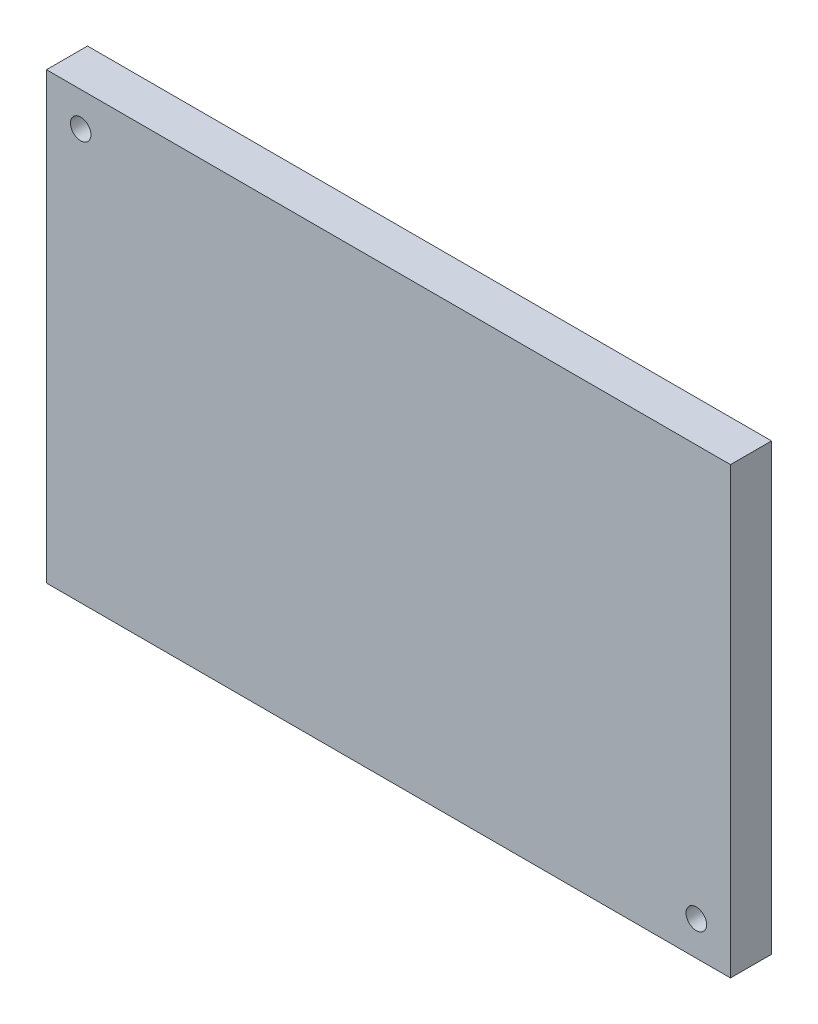
from build123d import *

# Parameters (mm, degrees)
ESQUISSE1_W             = 100
ESQUISSE1_H             = 65
BOSS_EXTRU_1_DEPTH      = 6
ESQUISSE2_R             = 1.5
ENL_V_MAT_EXTRU_1_DEPTH = 6


with BuildPart() as part:
    # Esquisse1 → Boss.-Extru.1 (new body)
    with BuildSketch(Plane.XY):
        Rectangle(ESQUISSE1_W, ESQUISSE1_H)
    extrude(amount=BOSS_EXTRU_1_DEPTH)

    # Esquisse2 → Enlèv. mat.-Extru.1 (cut)
    with BuildSketch(Plane.XY.offset(6)):
        with Locations((-45, 27.5)):
            Circle(ESQUISSE2_R)
        with Locations((45, -27.5)):
            Circle(ESQUISSE2_R)
    extrude(amount=-ENL_V_MAT_EXTRU_1_DEPTH, mode=Mode.SUBTRACT)


solid = part.part
